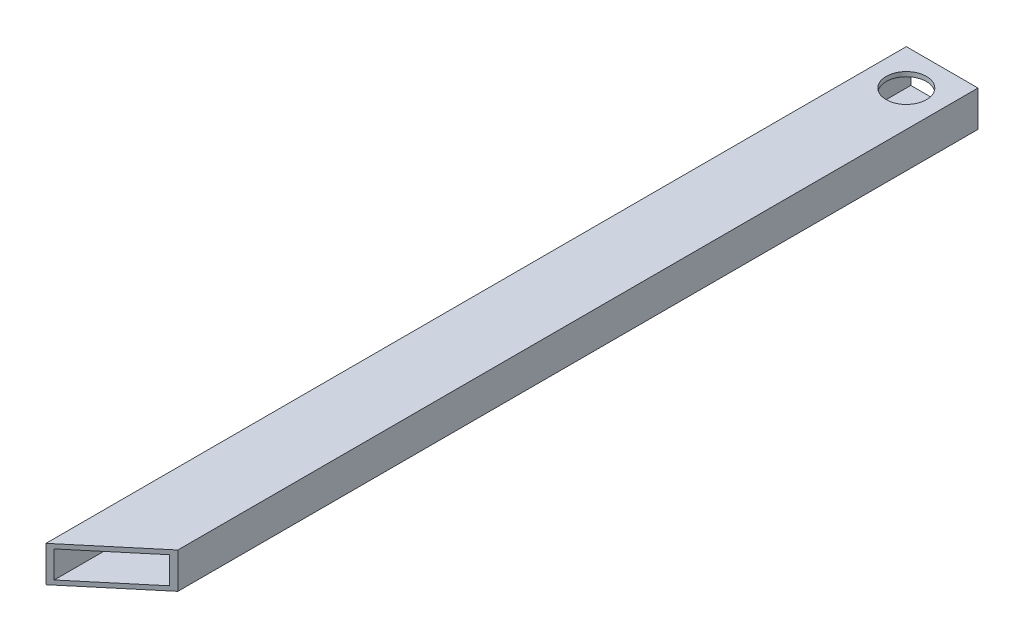
from build123d import *

# Parameters (mm, degrees)
SKETCH1_W           = 50.8
SKETCH1_H           = 25.4
BOSS_EXTRUDE1_DEPTH = 609.6
SKETCH2_W           = 44.45
SKETCH2_H           = 19.05
CUT_EXTRUDE1_DEPTH  = 609.6
SKETCH6_R           = 14.2875
CUT_EXTRUDE5_DEPTH  = 25.4
CUT_EXTRUDE6_DEPTH  = 25.4
SKETCH8_R           = 14.2875
CUT_EXTRUDE7_DEPTH  = 3.175


with BuildPart() as part:
    # Sketch1 → Boss-Extrude1 (new body)
    with BuildSketch(Plane.XY):
        with Locations((25.4, 12.7)):
            Rectangle(SKETCH1_W, SKETCH1_H)
    extrude(amount=BOSS_EXTRUDE1_DEPTH)

    # Sketch2 → Cut-Extrude1 (cut)
    with BuildSketch(Plane(origin=(0, 0, 0), x_dir=(-1, 0, 0), z_dir=(0, 0, -1))):
        with Locations((-25.4, 12.7)):
            Rectangle(SKETCH2_W, SKETCH2_H)
    extrude(amount=-CUT_EXTRUDE1_DEPTH, mode=Mode.SUBTRACT)

    # Sketch6 → Cut-Extrude5 (cut)
    with BuildSketch(Plane(origin=(0, 25.4, 0), x_dir=(1, 0, 0), z_dir=(0, 1, 0))):
        with Locations((25.4, -25.4)):
            Circle(SKETCH6_R)
    extrude(amount=-CUT_EXTRUDE5_DEPTH, mode=Mode.SUBTRACT)

    # Sketch7 → Cut-Extrude6 (cut)
    with BuildSketch(Plane(origin=(0, 25.4, 0), x_dir=(1, 0, 0), z_dir=(0, 1, 0))):
        Polygon((50.8, -566.973738736), (50.8, -609.6), (0, -609.6), align=None)
    extrude(amount=-CUT_EXTRUDE6_DEPTH, mode=Mode.SUBTRACT)

    # Sketch8 → Cut-Extrude7 (cut)
    with BuildSketch(Plane.XZ):
        with Locations((25.4, 522.762581257)):
            Circle(SKETCH8_R)
    extrude(amount=-CUT_EXTRUDE7_DEPTH, mode=Mode.SUBTRACT)


solid = part.part
